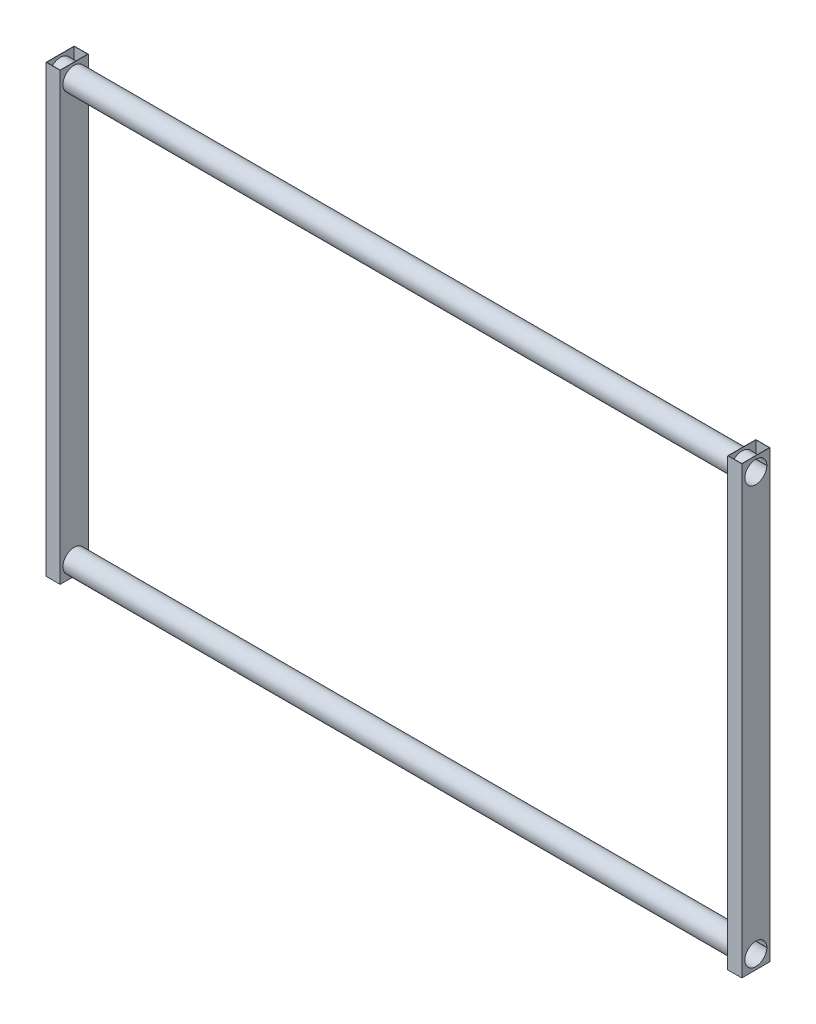
from build123d import *

# Parameters (mm, degrees)
SKETCH3_W             = 50.5
SKETCH3_H             = 101
SKETCH3_W_2           = 48.5
SKETCH3_H_2           = 99
BOSS_EXTRUDE1_DEPTH   = 1600
BOSS_EXTRUDE1_2_DEPTH = 1600
SKETCH4_R             = 39.5
CUT_EXTRUDE1_DEPTH    = 1
SKETCH5_R             = 39.5
CUT_EXTRUDE2_DEPTH    = 1
SKETCH6_R             = 40.5
CUT_EXTRUDE3_DEPTH    = 2401
BOSS_EXTRUDE2_DEPTH   = 2498


with BuildPart() as part:
    # Sketch3 → Boss-Extrude1 (new body)
    with BuildSketch(Plane(origin=(0, 0, 0), x_dir=(1, 0, 0), z_dir=(0, 1, 0))):
        with Locations((-25.25, 0)):
            Rectangle(SKETCH3_W, SKETCH3_H)
        with Locations((-25.25, 0)):
            Rectangle(SKETCH3_W_2, SKETCH3_H_2, mode=Mode.SUBTRACT)
    extrude(amount=BOSS_EXTRUDE1_DEPTH)

    # Sketch5 → Cut-Extrude2 (cut)
    with BuildSketch(Plane.ZY.offset(50.5)):
        with Locations((0, 50)):
            Circle(SKETCH5_R)
        with Locations((0, 1550)):
            Circle(SKETCH5_R)
    extrude(amount=-CUT_EXTRUDE2_DEPTH, mode=Mode.SUBTRACT)


with BuildPart() as body_2:
    # Sketch3 → Boss-Extrude1 2 (new body)
    with BuildSketch(Plane(origin=(0, 0, 0), x_dir=(1, 0, 0), z_dir=(0, 1, 0))):
        with Locations((2424.25, 0)):
            Rectangle(SKETCH3_W, SKETCH3_H)
        with Locations((2424.25, 0)):
            Rectangle(SKETCH3_W_2, SKETCH3_H_2, mode=Mode.SUBTRACT)
    extrude(amount=BOSS_EXTRUDE1_2_DEPTH)

    # Sketch4 → Cut-Extrude1 (cut)
    with BuildSketch(Plane(origin=(2449.5, 0, 0), x_dir=(0, 0, -1), z_dir=(1, 0, 0))):
        with Locations((0, 50)):
            Circle(SKETCH4_R)
        with Locations((0, 1550)):
            Circle(SKETCH4_R)
    extrude(amount=-CUT_EXTRUDE1_DEPTH, mode=Mode.SUBTRACT)


with BuildPart() as cut_extrude3_tool:
    # Sketch6 → Cut-Extrude3 (new body)
    with BuildSketch(Plane(origin=(2400, 0, 0), x_dir=(0, 0, -1), z_dir=(1, 0, 0))):
        with Locations((0, 50)):
            Circle(SKETCH6_R)
        with Locations((0, 1550)):
            Circle(SKETCH6_R)
    extrude(amount=-CUT_EXTRUDE3_DEPTH)


with BuildPart() as part_1:
    add(part.part)

    # Cut-Extrude3: cut by cut_extrude3_tool
    add(cut_extrude3_tool.part, mode=Mode.SUBTRACT)



with BuildPart() as body_2_1:
    add(body_2.part)

    # Cut-Extrude3: cut by cut_extrude3_tool
    add(cut_extrude3_tool.part, mode=Mode.SUBTRACT)


with BuildPart() as part_2:
    add(part_1.part)

    add(body_2_1.part)  # Boss-Extrude2 merges body 2
    # Sketch7 → Boss-Extrude2 (add)
    with BuildSketch(Plane.ZY.offset(-2448.5)):
        with BuildLine():
            Line((-39.496835316, 50.5), (-40.496913463, 50.5))
            ThreePointArc((-40.496913463, 50.5), (40.5, 50), (-40.496913463, 49.5))
            Line((-40.496913463, 49.5), (-39.496835316, 49.5))
            ThreePointArc((-39.496835316, 49.5), (39.5, 50), (-39.496835316, 50.5))
        make_face()
        with BuildLine():
            Line((-40.496913463, 1550.5), (-39.496835316, 1550.5))
            ThreePointArc((-39.496835316, 1550.5), (39.5, 1550), (-39.496835316, 1549.5))
            Line((-39.496835316, 1549.5), (-40.496913463, 1549.5))
            ThreePointArc((-40.496913463, 1549.5), (40.5, 1550), (-40.496913463, 1550.5))
        make_face()
    extrude(amount=BOSS_EXTRUDE2_DEPTH)


solid = part_2.part
